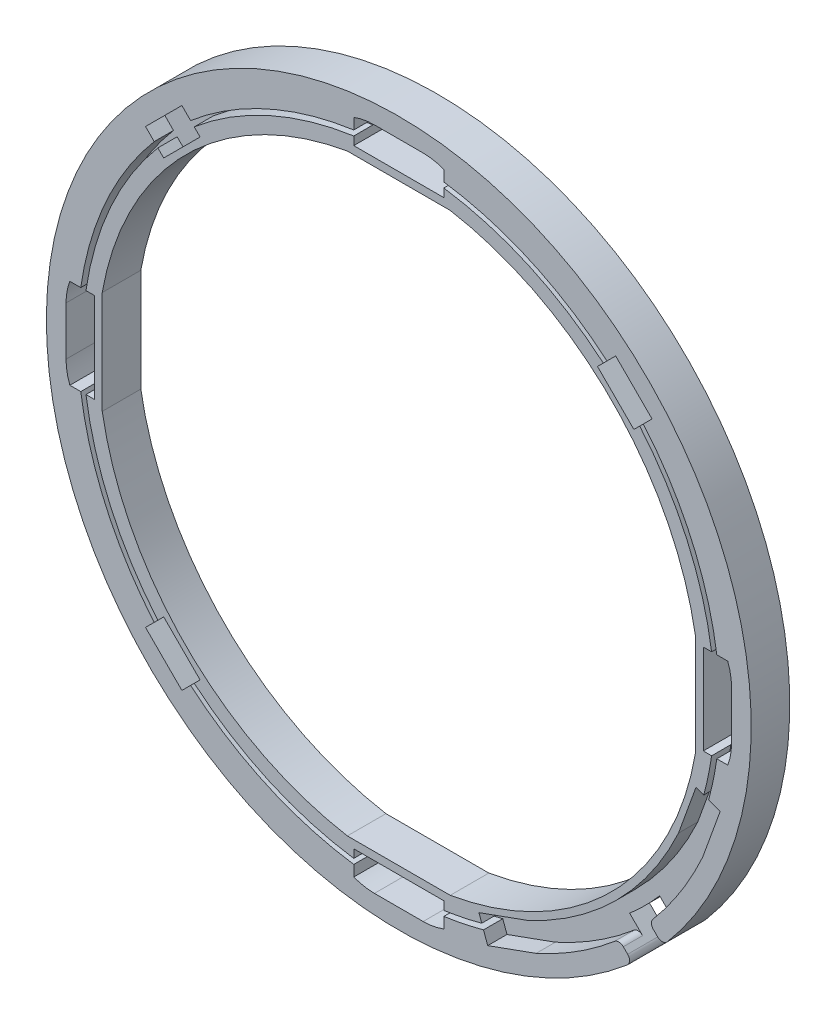
from build123d import *

# Parameters (mm, degrees)
SKETCH2_R       = 27.4
EXTRUDE1_DEPTH  = 3
EXTRUDE2_DEPTH  = 3
SKETCH5_R       = 24.971147558
SKETCH5_R_2     = 24.571147558
EXTRUDE3_DEPTH  = 1.5
EXTRUDE4_DEPTH  = 1.5
EXTRUDE11_DEPTH = 3.8
EXTRUDE12_DEPTH = 1.5
FILLET1_R       = 0.5


with BuildPart() as part:
    # Sketch2 → Extrude1 (new body)
    with BuildSketch(Plane.XY):
        Circle(SKETCH2_R)
        with BuildLine():
            Line((-4, 23.055585007), (4, 23.055585007))
            ThreePointArc((4, 23.055585007), (16.54629868, 16.54629868), (23.055585007, 4))
            Line((23.055585007, 4), (23.055585007, -4))
            ThreePointArc((23.055585007, -4), (16.54629868, -16.54629868), (4, -23.055585007))
            Line((4, -23.055585007), (-4, -23.055585007))
            ThreePointArc((-4, -23.055585007), (-16.54629868, -16.54629868), (-23.055585007, -4))
            Line((-23.055585007, -4), (-23.055585007, 4))
            ThreePointArc((-23.055585007, 4), (-16.54629868, 16.54629868), (-4, 23.055585007))
        make_face(mode=Mode.SUBTRACT)
    extrude(amount=EXTRUDE1_DEPTH)

    # Sketch3 → Extrude2 (cut)
    with BuildSketch(Plane.XY.offset(3)):
        with BuildLine():
            Line((-1.893881028, 25.871147558), (1.893881028, 25.871147558))
            ThreePointArc((1.893881028, 25.871147558), (2.710560642, 25.796258258), (3.5, 25.574088282))
            Line((3.5, 25.574088282), (3.5, 23.671147558))
            Line((3.5, 23.671147558), (-3.5, 23.671147558))
            Line((-3.5, 23.671147558), (-3.5, 25.574088282))
            ThreePointArc((-3.5, 25.574088282), (-2.710560642, 25.796258258), (-1.893881028, 25.871147558))
        make_face()
        with BuildLine():
            Line((23.671147558, -3.5), (23.671147558, 3.5))
            Line((23.671147558, 3.5), (25.574088282, 3.5))
            ThreePointArc((25.574088282, 3.5), (25.796258258, 2.710560642), (25.871147558, 1.893881028))
            Line((25.871147558, 1.893881028), (25.871147558, -1.893881028))
            ThreePointArc((25.871147558, -1.893881028), (25.796258258, -2.710560642), (25.574088282, -3.5))
            Line((25.574088282, -3.5), (23.671147558, -3.5))
        make_face()
        with BuildLine():
            Line((-3.5, -23.671147558), (3.5, -23.671147558))
            Line((3.5, -23.671147558), (3.5, -25.574088282))
            ThreePointArc((3.5, -25.574088282), (2.710560642, -25.796258258), (1.893881028, -25.871147558))
            Line((1.893881028, -25.871147558), (-1.893881028, -25.871147558))
            ThreePointArc((-1.893881028, -25.871147558), (-2.710560642, -25.796258258), (-3.5, -25.574088282))
            Line((-3.5, -25.574088282), (-3.5, -23.671147558))
        make_face()
        with BuildLine():
            Line((-23.671147558, 3.5), (-23.671147558, -3.5))
            Line((-23.671147558, -3.5), (-25.574088282, -3.5))
            ThreePointArc((-25.574088282, -3.5), (-25.796258258, -2.710560642), (-25.871147558, -1.893881028))
            Line((-25.871147558, -1.893881028), (-25.871147558, 1.893881028))
            ThreePointArc((-25.871147558, 1.893881028), (-25.796258258, 2.710560642), (-25.574088282, 3.5))
            Line((-25.574088282, 3.5), (-23.671147558, 3.5))
        make_face()
    extrude(amount=-EXTRUDE2_DEPTH, mode=Mode.SUBTRACT)

    # Sketch5 → Extrude3 (cut)
    with BuildSketch(Plane.XY.offset(3)):
        Circle(SKETCH5_R)
        Circle(SKETCH5_R_2, mode=Mode.SUBTRACT)
    extrude(amount=-EXTRUDE3_DEPTH, mode=Mode.SUBTRACT)

    # Sketch6 → Extrude4 (cut)
    with BuildSketch(Plane.XY.offset(3)):
        Polygon((-19.691237457, 16.862810332), (-18.277023894, 15.448596769), (-15.448596769, 18.277023894), (-16.862810332, 19.691237457), align=None)
        Polygon((16.862810332, 19.691237457), (19.691237457, 16.862810332), (18.277023894, 15.448596769), (15.448596769, 18.277023894), align=None)
        Polygon((-19.691237457, -16.862810332), (-18.277023894, -15.448596769), (-15.448596769, -18.277023894), (-16.862810332, -19.691237457), align=None)
        Polygon((6.912025, -24.986458638), (6.231672227, -23.105735345), (9.993118813, -21.745029799), (10.673471586, -23.625753092), align=None)
        Polygon((24.986458638, -6.912025), (23.105735345, -6.231672227), (21.745029799, -9.993118813), (23.625753092, -10.673471586), align=None)
    extrude(amount=-EXTRUDE4_DEPTH, mode=Mode.SUBTRACT)

    # Sketch13 → Extrude11 (cut)
    with BuildSketch(Plane.XY.offset(3)):
        Polygon((19.975766569, -17.642314191), (18.785405345, -16.451952967), (17.936646698, -17.373396778), (17.373396778, -17.936646698), (16.451952967, -18.785405345), (17.642314191, -19.975766569), (19.180190393, -21.513642771), (21.513642771, -19.180190393), align=None)
    extrude(amount=-EXTRUDE11_DEPTH, mode=Mode.SUBTRACT)

    # Sketch14 → Extrude12 (cut)
    with BuildSketch(Plane.XY.offset(3)):
        with BuildLine():
            Line((10.673471586, -23.625753092), (10.279766704, -22.537420726))
            Line((10.279766704, -22.537420726), (9.993118813, -21.745029799))
            ThreePointArc((9.993118813, -21.745029799), (12.986268088, -20.101382682), (15.715013126, -18.048465504))
            ThreePointArc((15.715013126, -18.048465504), (16.922008518, -16.922008518), (18.048465504, -15.715013126))
            ThreePointArc((18.048465504, -15.715013126), (20.101382682, -12.986268088), (21.745029799, -9.993118813))
            Line((21.745029799, -9.993118813), (22.537420726, -10.279766704))
            Line((22.537420726, -10.279766704), (23.625753092, -10.673471586))
            ThreePointArc((23.625753092, -10.673471586), (21.783851689, -14.055710955), (19.461215863, -17.127763485))
            Line((19.461215863, -17.127763485), (17.127763485, -19.461215863))
            ThreePointArc((17.127763485, -19.461215863), (14.055710955, -21.783851689), (10.673471586, -23.625753092))
        make_face()
    extrude(amount=-EXTRUDE12_DEPTH, mode=Mode.SUBTRACT)

    # Fillet1
    fillet1_edges = [part.edges().sort_by_distance(p)[0] for p in [
        (20.506290558, -18.17283818, 1.5),
        (18.17283818, -20.506290558, 1.5),
        (17.127763485, -19.461215863, 2.25),
        (19.461215863, -17.127763485, 2.25),
    ]]
    fillet(fillet1_edges, radius=FILLET1_R)


solid = part.part
